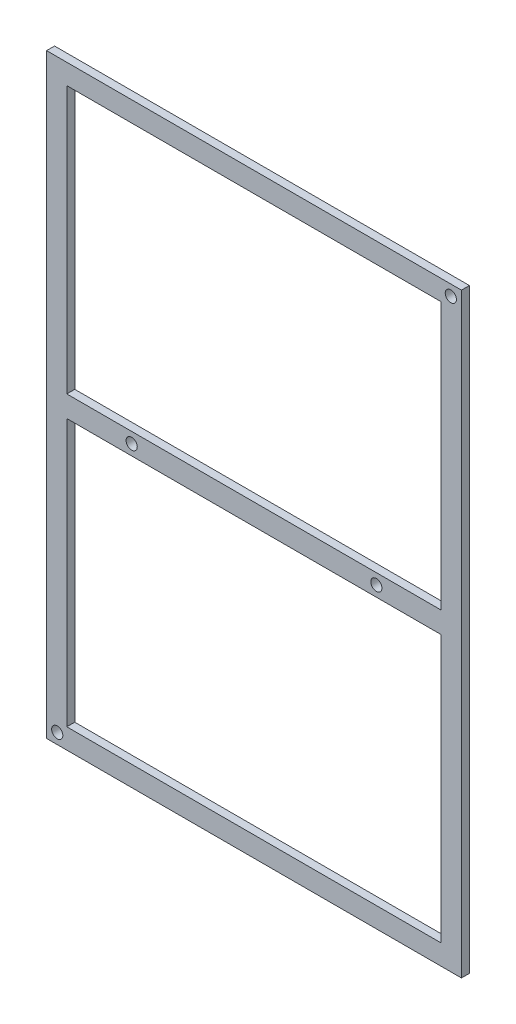
from build123d import *

# Parameters (mm, degrees)
SKETCH1_W           = 78
SKETCH1_H           = 112
SKETCH1_W_2         = 70.4
SKETCH1_H_2         = 104.4
BOSS_EXTRUDE1_DEPTH = 1.5
SKETCH2_W           = 70.4
SKETCH2_H           = 4
BOSS_EXTRUDE3_DEPTH = 1.5
SKETCH4_R           = 1.05
CUT_EXTRUDE1_DEPTH  = 2.5


with BuildPart() as part:
    # Sketch1 → Boss-Extrude1 (new body)
    with BuildSketch(Plane.XY):
        Rectangle(SKETCH1_W, SKETCH1_H)
        Rectangle(SKETCH1_W_2, SKETCH1_H_2, mode=Mode.SUBTRACT)
    extrude(amount=BOSS_EXTRUDE1_DEPTH)

    # Sketch2 → Boss-Extrude3 (add)
    with BuildSketch(Plane.XY.offset(1.5)):
        Rectangle(SKETCH2_W, SKETCH2_H)
    extrude(amount=-BOSS_EXTRUDE3_DEPTH)

    # Sketch4 → Cut-Extrude1 (cut, through all)
    with BuildSketch(Plane.XY.offset(1.5)):
        with Locations((37, 54)):
            Circle(SKETCH4_R)
        with Locations((23, 0)):
            Circle(SKETCH4_R)
        with Locations((-23, 0)):
            Circle(SKETCH4_R)
        with Locations((-37, -54)):
            Circle(SKETCH4_R)
    extrude(amount=-CUT_EXTRUDE1_DEPTH, mode=Mode.SUBTRACT)


solid = part.part
